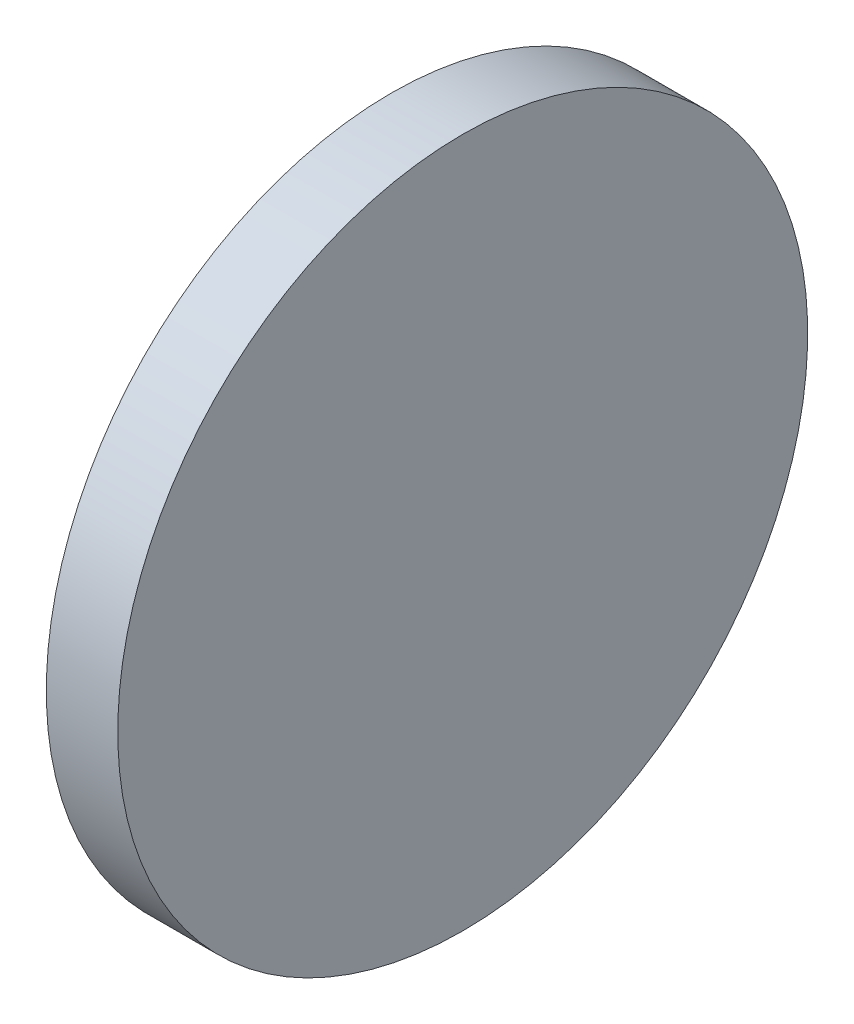
from build123d import *


with BuildPart() as part:
    # 草图1 → 旋转1 (revolve)
    with BuildSketch(Plane.XY):
        with BuildLine():
            Line((122.787601258, 77.716840471), (125.376516612, 77.716840471))
            ThreePointArc((125.376516612, 77.716840471), (125.327687273, 71.466925246), (125.311410679, 65.216840471))
            Line((125.311410679, 65.216840471), (122.611410679, 65.216840471))
            ThreePointArc((122.611410679, 65.216840471), (122.655460511, 71.467461303), (122.787601258, 77.716840471))
        make_face()
    revolve(axis=Axis((115.944491298, 65.216840471, 0), (1, 0, 0)))


solid = part.part
